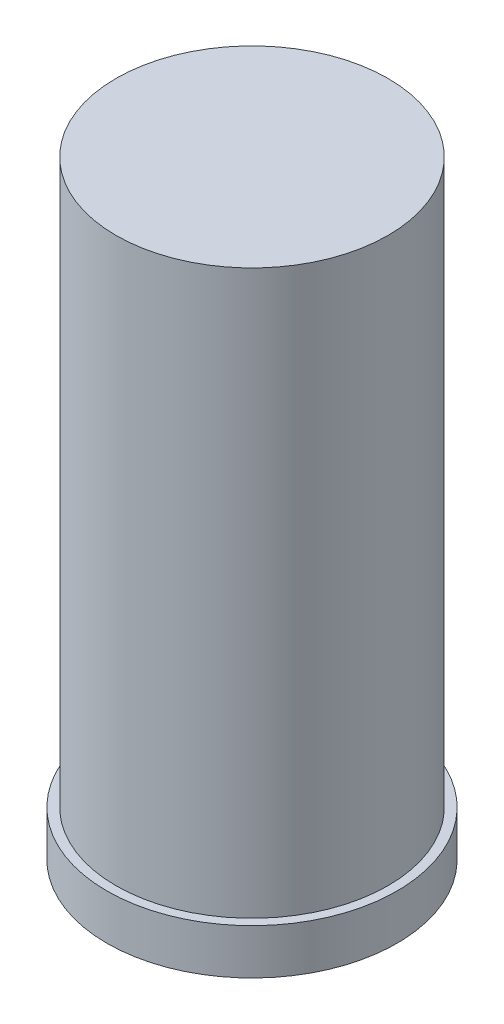
from build123d import *

# Parameters (mm, degrees)
SKETCH1_R           = 15
BOSS_EXTRUDE1_DEPTH = 67.12
SKETCH1_3_R         = 4
CUT_EXTRUDE1_DEPTH  = 7
SKETCH1_4_R         = 16
SKETCH1_4_R_2       = 15
BOSS_EXTRUDE2_DEPTH = 5


with BuildPart() as part:
    # Sketch1 → Boss-Extrude1 (new body)
    with BuildSketch(Plane(origin=(0, 0, 0), x_dir=(1, 0, 0), z_dir=(0, 1, 0))):
        Circle(SKETCH1_R)
    extrude(amount=BOSS_EXTRUDE1_DEPTH)

    # Sketch1_3 → Cut-Extrude1 (cut)
    with BuildSketch(Plane(origin=(0, 0, 0), x_dir=(1, 0, 0), z_dir=(0, 1, 0))):
        Circle(SKETCH1_3_R)
    extrude(amount=CUT_EXTRUDE1_DEPTH, mode=Mode.SUBTRACT)

    # Sketch1_4 → Boss-Extrude2 (add)
    with BuildSketch(Plane(origin=(0, 0, 0), x_dir=(1, 0, 0), z_dir=(0, 1, 0))):
        Circle(SKETCH1_4_R)
        Circle(SKETCH1_4_R_2, mode=Mode.SUBTRACT)
    extrude(amount=BOSS_EXTRUDE2_DEPTH)


solid = part.part
